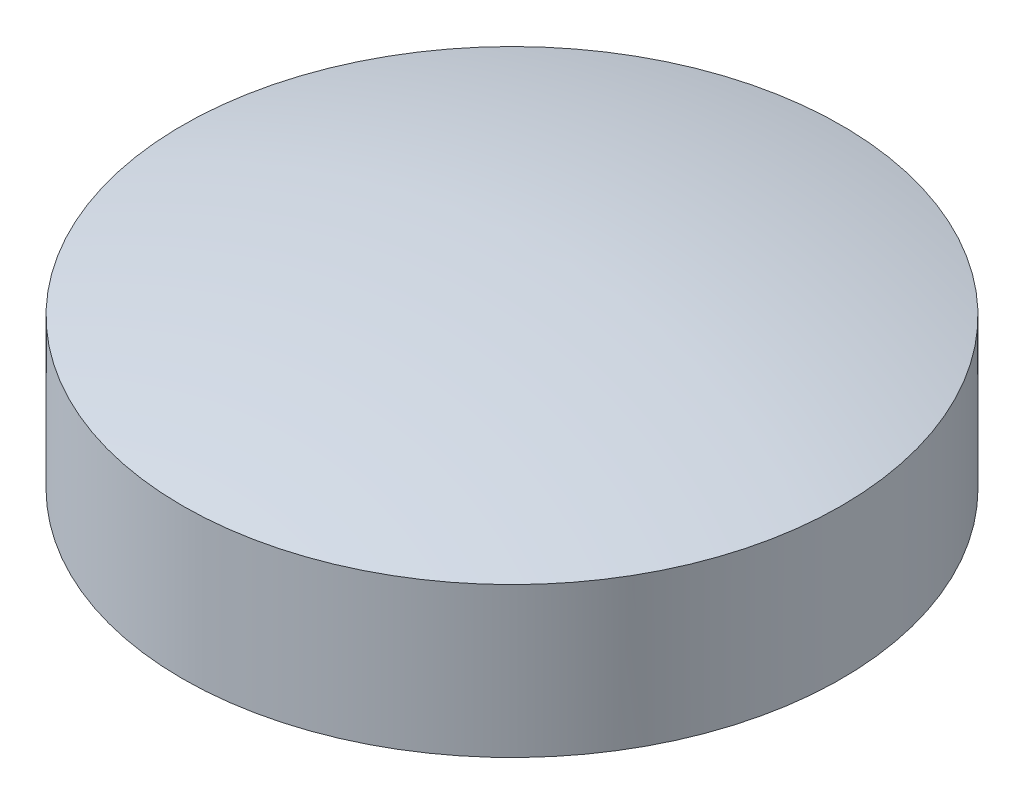
from build123d import *

# Parameters (mm, degrees)
SKETCH2_R          = 1.5
CUT_EXTRUDE1_DEPTH = 5


with BuildPart() as part:
    # Sketch1 → Revolve1 (revolve)
    with BuildSketch(Plane.XY, mode=Mode.PRIVATE) as revolve1_sk:
        with BuildLine():
            Line((22, 0), (0, 0))
            Line((0, 0), (0, 10))
            ThreePointArc((0, 10), (10.898198344, 12.246545474), (22, 13))
            Line((22, 13), (22, 0))
        make_face()
    revolve(revolve1_sk.sketch.rotate(Axis((22, 29.706407995, 0), (0, -1, 0)), 180), axis=Axis((22, 29.706407995, 0), (0, -1, 0)))  # turned: the seam where the file's is

    # Sketch2 → Cut-Extrude1 (cut)
    with BuildSketch(Plane.XZ):
        Circle(SKETCH2_R)
    extrude(amount=-CUT_EXTRUDE1_DEPTH, mode=Mode.SUBTRACT)


solid = part.part
